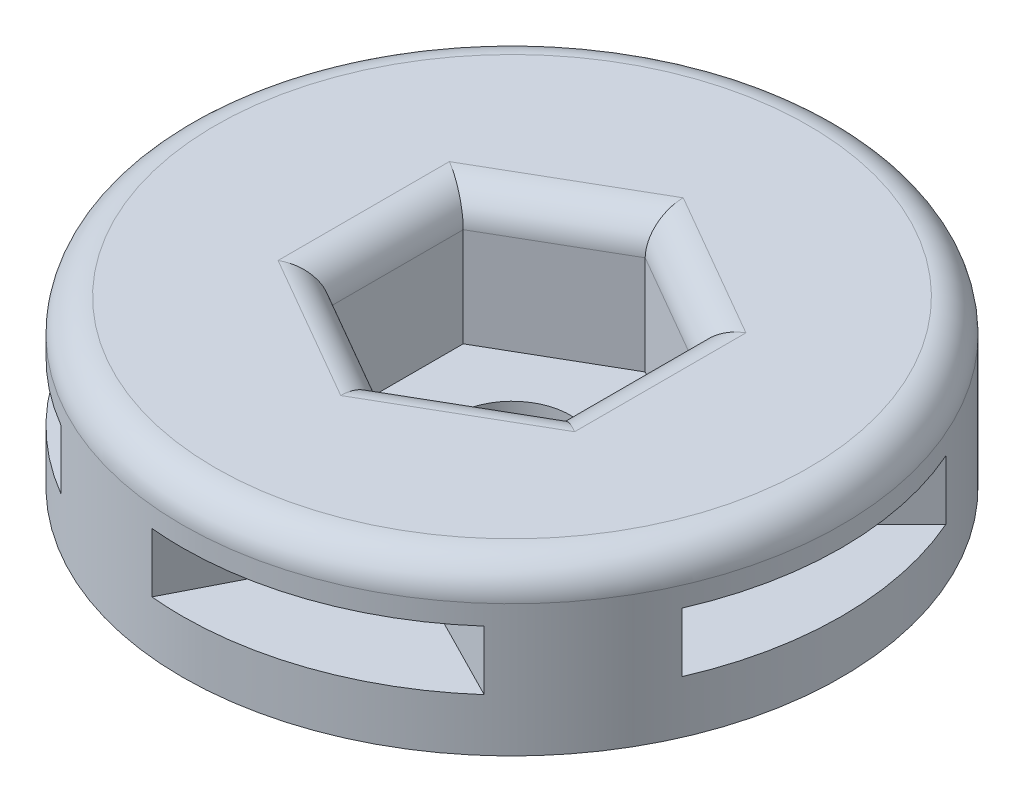
from build123d import *

# Parameters (mm, degrees)
SKETCH2_R            = 12.7
BOSS_EXTRUDE1_DEPTH  = 3.175
CUT_EXTRUDE1_DEPTH   = 1.143
CIRPATTERN1_COUNT    = 5
FILLET1_R            = 1.27
BOSS_EXTRUDE2_DEPTH  = 1.27
M4_CLEARANCE_HOLE1_D = 4.5


with BuildPart() as part:
    # Sketch2 → Boss-Extrude1 (new, symmetric)
    with BuildSketch(Plane(origin=(0, 0, 0), x_dir=(1, 0, 0), z_dir=(0, 1, 0))):
        Circle(SKETCH2_R)
        Polygon((0, 5.132643893), (-4.445, 2.566321947), (-4.445, -2.566321947), (0, -5.132643893), (4.445, -2.566321947), (4.445, 2.566321947), align=None, mode=Mode.SUBTRACT)
    extrude(amount=BOSS_EXTRUDE1_DEPTH, both=True)

    # Sketch3 → Cut-Extrude1 (cut, symmetric)
    with BuildSketch(Plane(origin=(0, 0, 0), x_dir=(1, 0, 0), z_dir=(0, 1, 0))):
        with BuildLine():
            Line((11.639742265, 5.08), (7.829742265, 1.27))
            Line((7.829742265, 1.27), (7.829742265, -1.27))
            Line((7.829742265, -1.27), (11.639742265, -5.08))
            ThreePointArc((11.639742265, -5.08), (12.7, 0), (11.639742265, 5.08))
        make_face()
    cut_extrude1 = extrude(amount=CUT_EXTRUDE1_DEPTH, both=True, mode=Mode.SUBTRACT)

    # CirPattern1: Cut-Extrude1 ×5 about axis
    cirpattern1_axis = Axis((0, -3.4925, 0), (0, 1, 0))
    for i in range(1, CIRPATTERN1_COUNT):
        add(cut_extrude1.rotate(cirpattern1_axis, i * 360 / CIRPATTERN1_COUNT), mode=Mode.SUBTRACT)

    # Fillet1
    fillet1_edges = [part.edges().sort_by_distance(p)[0] for p in [
        (-12.7, 3.175, 0),
        (-4.445, 3.175, 0),
        (-2.2225, 3.175, 3.84948292),
        (2.2225, 3.175, 3.84948292),
        (4.445, 3.175, 0),
        (2.2225, 3.175, -3.84948292),
        (-2.2225, 3.175, -3.84948292),
    ]]
    fillet(fillet1_edges, radius=FILLET1_R)

    # Sketch4 → Boss-Extrude2 (add)
    with BuildSketch(Plane.XZ.offset(3.175)):
        Polygon((4.445, 2.566321947), (4.445, -2.566321947), (0, -5.132643893), (-4.445, -2.566321947), (-4.445, 2.566321947), (0, 5.132643893), align=None)
    extrude(amount=-BOSS_EXTRUDE2_DEPTH)

    # M4 Clearance Hole1 (through all)
    with Locations(Plane(origin=(0, -1.905, 0), x_dir=(1, 0, 0), z_dir=(0, 1, 0))):
        with Locations((0, 0)):
            Hole(M4_CLEARANCE_HOLE1_D / 2)


solid = part.part
